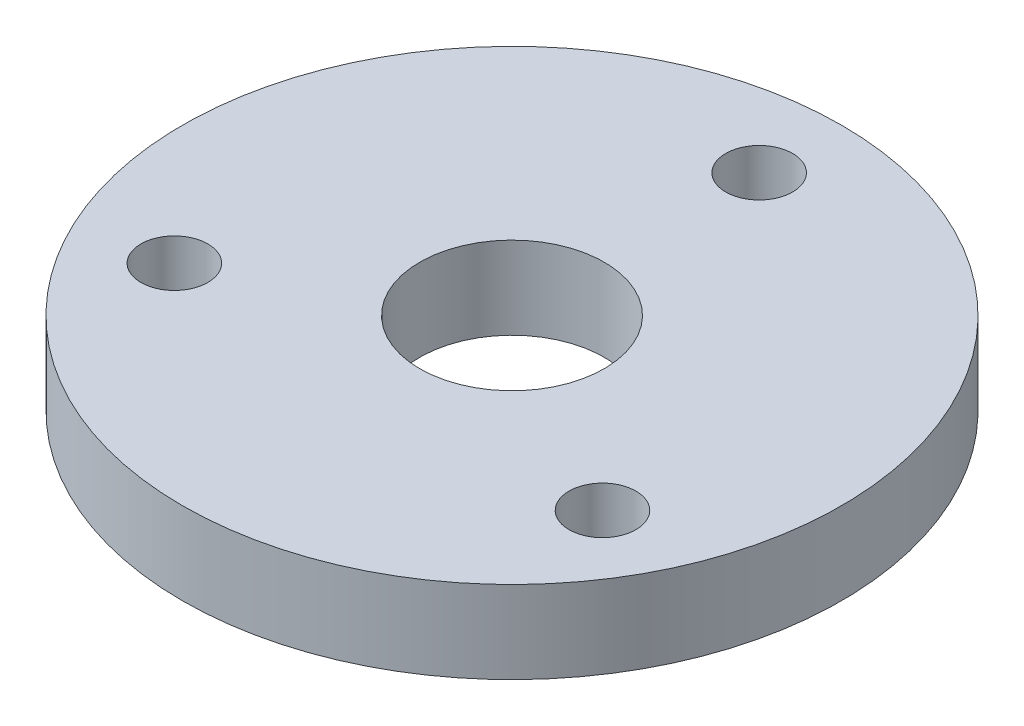
from build123d import *

# Parameters (mm, degrees)
SKETCH1_R           = 100
SKETCH1_R_2         = 28
SKETCH1_R_3         = 10.15
BOSS_EXTRUDE1_DEPTH = 25


with BuildPart() as part:
    # Sketch1 → Boss-Extrude1 (new body)
    with BuildSketch(Plane(origin=(0, 0, 0), x_dir=(1, 0, 0), z_dir=(0, 1, 0))):
        Circle(SKETCH1_R)
        Circle(SKETCH1_R_2, mode=Mode.SUBTRACT)
        with Locations((0, 75)):
            Circle(SKETCH1_R_3, mode=Mode.SUBTRACT)
        with Locations((64.951905284, -37.5)):
            Circle(SKETCH1_R_3, mode=Mode.SUBTRACT)
        with Locations((-64.951905284, -37.5)):
            Circle(SKETCH1_R_3, mode=Mode.SUBTRACT)
    extrude(amount=BOSS_EXTRUDE1_DEPTH)


solid = part.part
